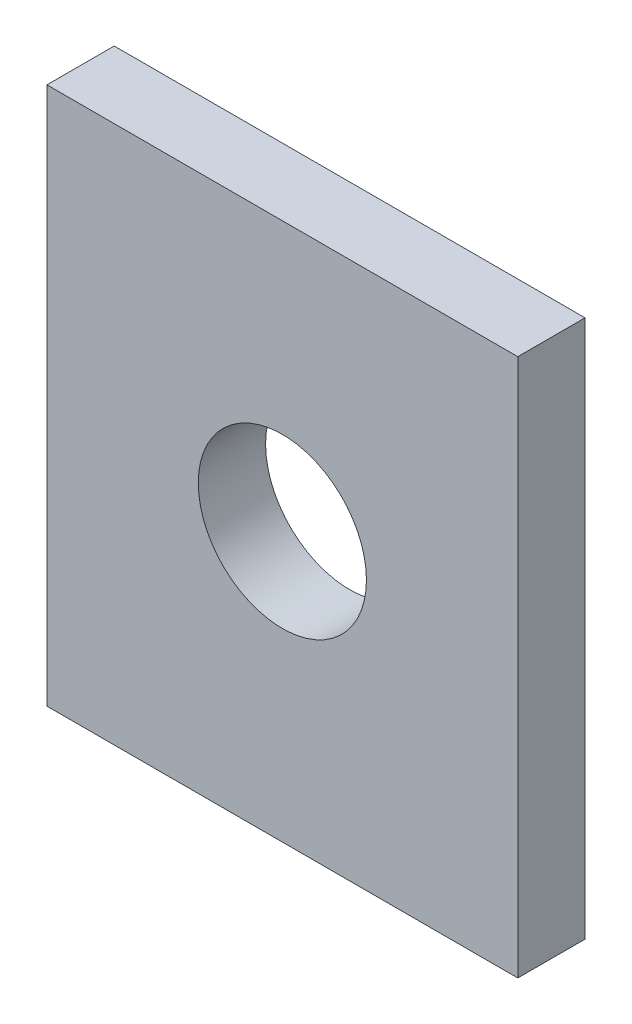
from build123d import *

# Parameters (mm, degrees)
SKETCH1_W           = 35
SKETCH1_H           = 40
BOSS_EXTRUDE1_DEPTH = 2.5
SKETCH2_R           = 6.25
CUT_EXTRUDE1_DEPTH  = 6


with BuildPart() as part:
    # Sketch1 → Boss-Extrude1 (new body, symmetric)
    with BuildSketch(Plane.XY):
        Rectangle(SKETCH1_W, SKETCH1_H)
    extrude(amount=BOSS_EXTRUDE1_DEPTH, both=True)

    # Sketch2 → Cut-Extrude1 (cut, through all)
    with BuildSketch(Plane.XY.offset(2.5)):
        Circle(SKETCH2_R)
    extrude(amount=-CUT_EXTRUDE1_DEPTH, mode=Mode.SUBTRACT)


solid = part.part
